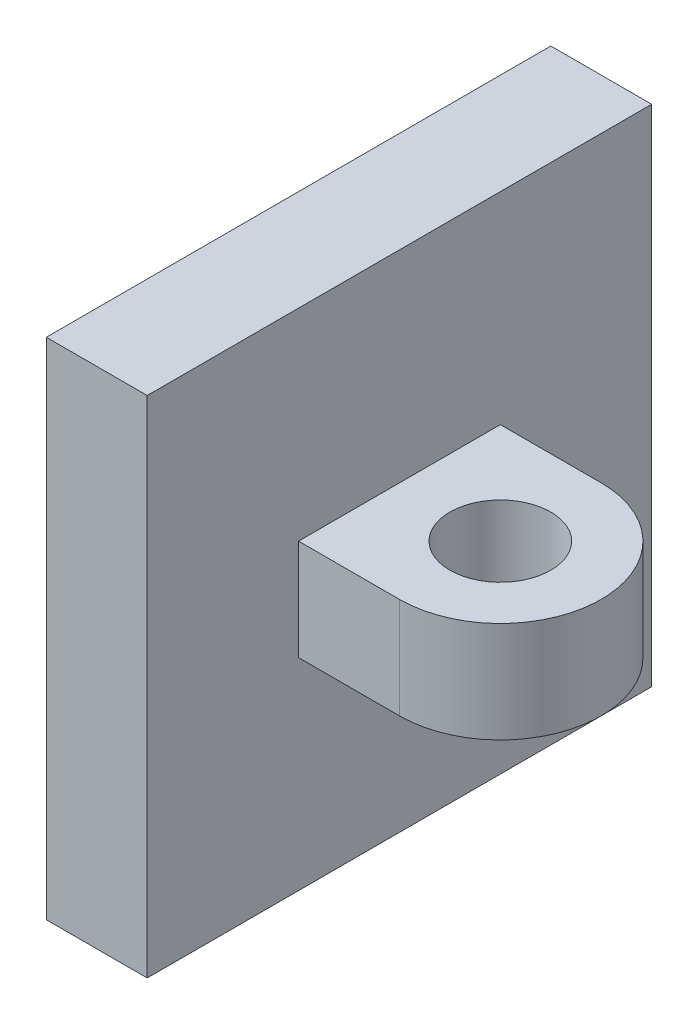
from build123d import *

# Parameters (mm, degrees)
SKETCH1_W           = 2
SKETCH1_H           = 10
BOSS_EXTRUDE1_DEPTH = 10
BOSS_EXTRUDE2_DEPTH = 5
SKETCH3_R           = 1
CUT_EXTRUDE1_DEPTH  = 15


with BuildPart() as part:
    # Sketch1 → Boss-Extrude1 (new body)
    with BuildSketch(Plane(origin=(0, 0, 0), x_dir=(1, 0, 0), z_dir=(0, 1, 0))):
        with Locations((0.229885057, -3.379310345)):
            Rectangle(SKETCH1_W, SKETCH1_H)
    extrude(amount=BOSS_EXTRUDE1_DEPTH)

    # Sketch2 → Boss-Extrude2 (add)
    with BuildSketch(Plane(origin=(1.229885057, 0, 0), x_dir=(0, 0, -1), z_dir=(1, 0, 0))):
        Polygon((-2.379310345, 4), (-4.379310345, 6), (-5.379310345, 6), (-5.379310345, 4), align=None)
        Polygon((-1.379310345, 6), (-4.379310345, 6), (-2.379310345, 4), (-1.379310345, 4), align=None)
    extrude(amount=BOSS_EXTRUDE2_DEPTH)

    # Sketch3 → Cut-Extrude1 (cut)
    with BuildSketch(Plane(origin=(0, 6, 0), x_dir=(1, 0, 0), z_dir=(0, 1, 0))):
        with Locations((3.229885057, -3.379310345)):
            Circle(SKETCH3_R)
        with BuildLine():
            Line((3.229885057, -1.379310345), (6.229885057, -1.379310345))
            Line((6.229885057, -1.379310345), (6.229885057, -5.379310345))
            Line((6.229885057, -5.379310345), (3.229885057, -5.379310345))
            ThreePointArc((3.229885057, -5.379310345), (5.229885057, -3.379310345), (3.229885057, -1.379310345))
        make_face()
    extrude(amount=-CUT_EXTRUDE1_DEPTH, mode=Mode.SUBTRACT)


solid = part.part
